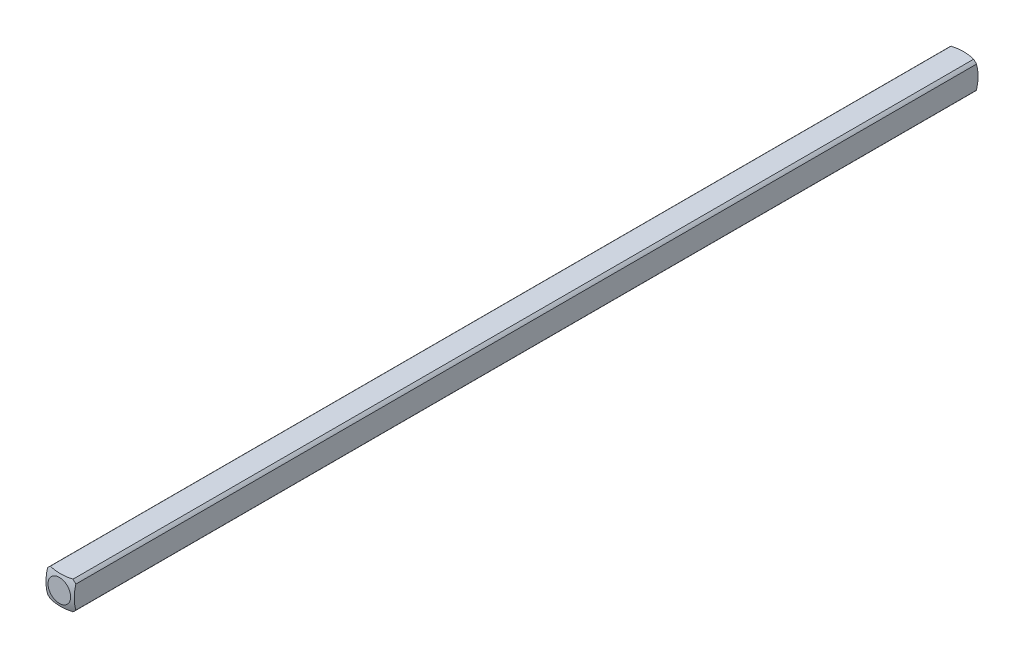
from build123d import *

# Parameters (mm, degrees)
SKETCH1_W           = 3.175
SKETCH1_H           = 3.175
BOSS_EXTRUDE1_DEPTH = 50.8
SKETCH2_OUTSIDE_W   = 15.376
SKETCH2_OUTSIDE_H   = 15.375
SKETCH2_OUTSIDE_R   = 2.032
CUT_EXTRUDE1_DEPTH  = 51.8


with BuildPart() as part:
    # Sketch1 → Boss-Extrude1 (new body)
    with BuildSketch(Plane.XY):
        Rectangle(SKETCH1_W, SKETCH1_H)
    extrude(amount=BOSS_EXTRUDE1_DEPTH)

    # Sketch2 outside → Cut-Extrude1 (cut, through all)
    with BuildSketch(Plane(origin=(0, 0, 0), x_dir=(-1, 0, 0), z_dir=(0, 0, -1))):
        with Locations((0, -0.0005)):
            Rectangle(SKETCH2_OUTSIDE_W, SKETCH2_OUTSIDE_H)
        Circle(SKETCH2_OUTSIDE_R, mode=Mode.SUBTRACT)
    extrude(amount=-CUT_EXTRUDE1_DEPTH, mode=Mode.SUBTRACT)

    # Sketch3 → Cut-Revolve1 (revolve, cut)
    with BuildSketch(Plane(origin=(0, 0, 0), x_dir=(1, 0, 0), z_dir=(0, 1, 0))):
        with BuildLine():
            Line((-5.053685963, -4.40273269), (-5.053685963, 5.740530545))
            Line((-5.053685963, 5.740530545), (0, 5.740530545))
            Line((0, 5.740530545), (0, 0.160877736))
            ThreePointArc((0, 0.160877736), (-3.404639553, -1.148866368), (-5.053685963, -4.40273269))
        make_face()
    revolve(axis=Axis((0, 0, 50.8), (0, 0, -1)), mode=Mode.SUBTRACT)

    # Mirror1: part across plane


with BuildPart() as part_1:
    add(part.part)
    add(part.part.mirror(Plane(origin=(0, 0, 50.8), x_dir=(1, 0, 0), z_dir=(0, 0, -1))))


solid = part_1.part
